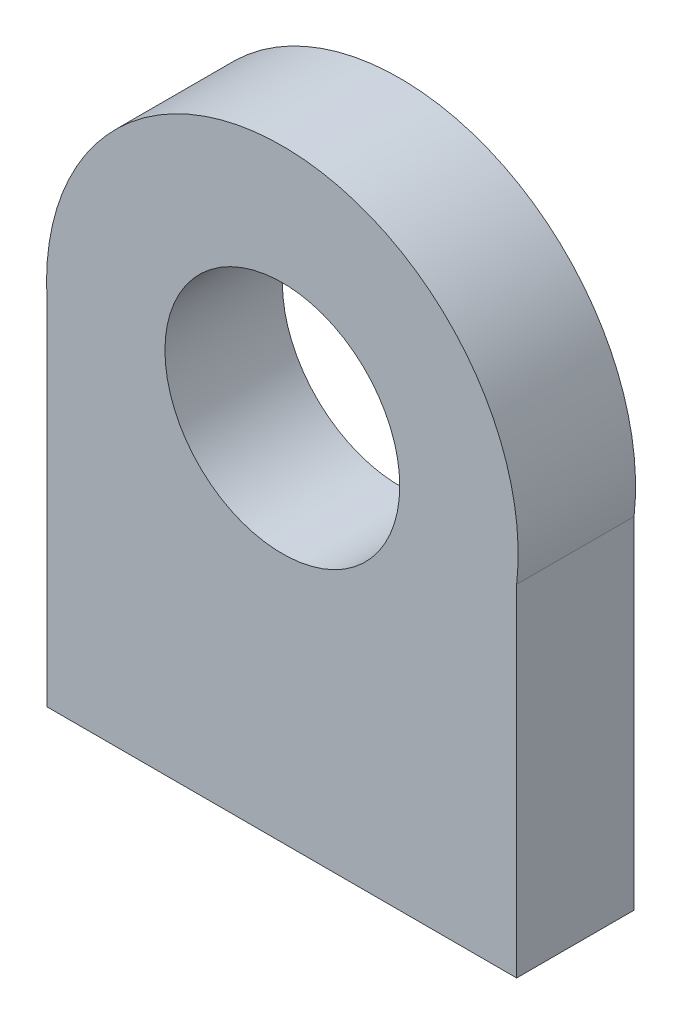
from build123d import *

# Parameters (mm, degrees)
CROQUIS1_R              = 10
SALIENTE_EXTRUIR1_DEPTH = 10


with BuildPart() as part:
    # Croquis1 → Saliente-Extruir1 (new body)
    with BuildSketch(Plane.XY):
        with BuildLine():
            Line((-21.861992619, 14.999798119), (-21.861992619, -15.000201881))
            Line((-21.861992619, -15.000201881), (18.138007381, -15.000201881))
            Line((18.138007381, -15.000201881), (18.138007381, 14.035372217))
            ThreePointArc((18.138007381, 14.035372217), (-1.334470444, 36.396805694), (-21.861992619, 14.999798119))
        make_face()
        with Locations((-1.818629215, 16.316101956)):
            Circle(CROQUIS1_R, mode=Mode.SUBTRACT)
    extrude(amount=SALIENTE_EXTRUIR1_DEPTH)


solid = part.part
